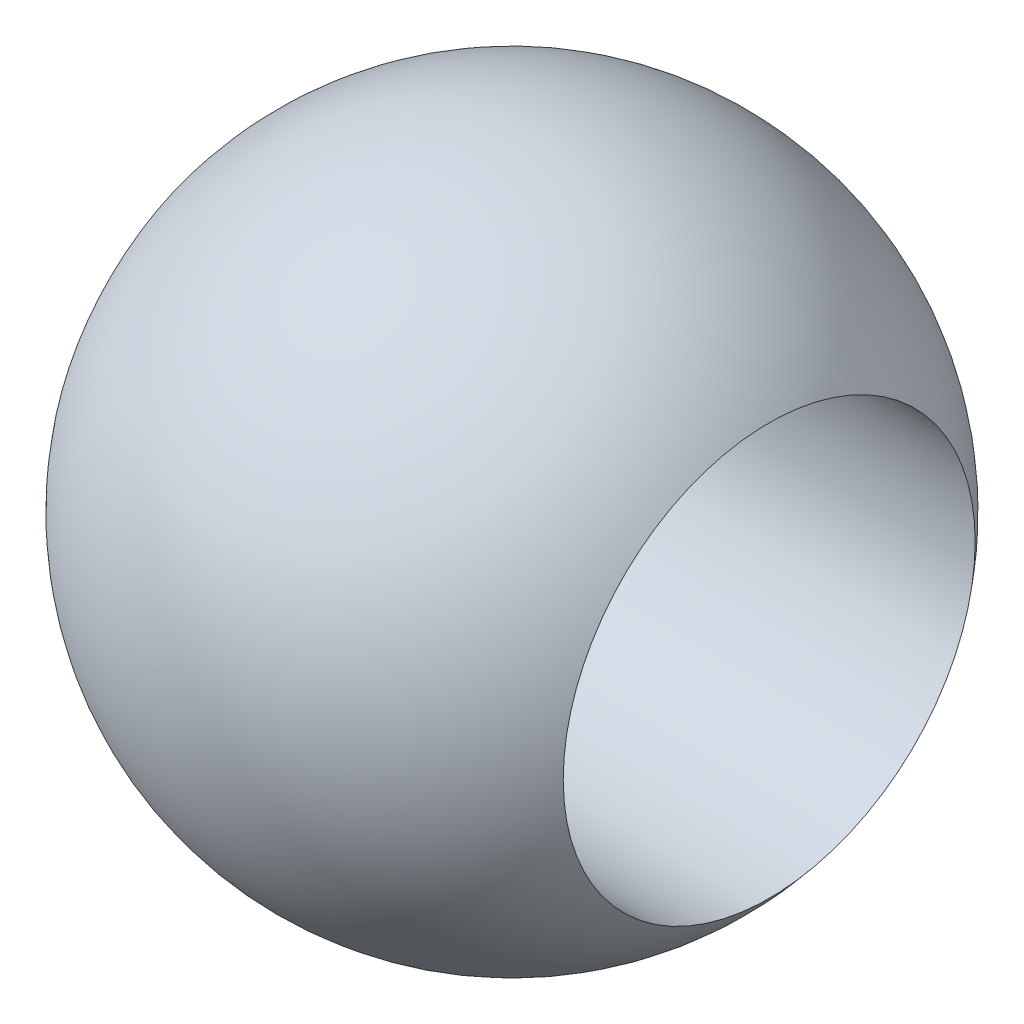
from build123d import *


with BuildPart() as part:
    # Sketch1 → Revolve1 (revolve)
    with BuildSketch(Plane.XY):
        with BuildLine():
            Line((-6.344917966, 5.08), (6.344917966, 5.08))
            ThreePointArc((6.344917966, 5.08), (0, 8.128), (-6.344917966, 5.08))
        make_face()
    revolve(axis=Axis((11.385897249, 0, 0), (-1, 0, 0)))


solid = part.part
